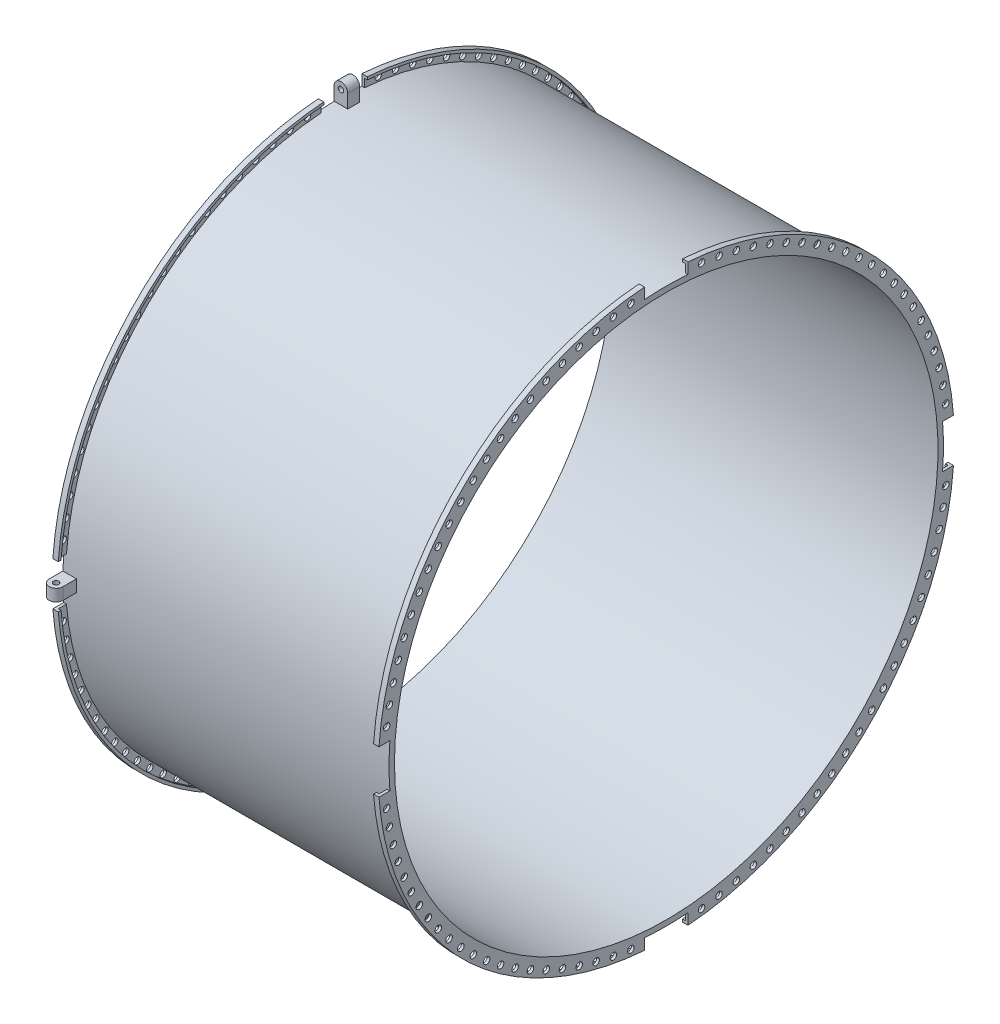
from build123d import *
from build123d.topology import SkipClean

# Parameters (mm, degrees)
KES_EKSTR_ZYON1_REACH       = 1306.531
IZIM4_R                     = 6
KES_EKSTR_ZYON2_DEPTH       = 600
IZIM5_R                     = 5
Y_KSEKLIK_EKSTR_ZYON1_DEPTH = 11
DAIRESEL_O_ALTMA11_COUNT    = 4


with BuildPart() as part:
    # Çizim1 → Döndür1 (revolve)
    with BuildSketch(Plane.XY, mode=Mode.PRIVATE) as d_nd_r1_sk:
        Polygon((0, 0), (0, 30), (10, 30), (10, 25), (5, 25), (5, 10), (595, 10), (595, 25), (590, 25), (590, 30), (600, 30), (600, 0), align=None)
    revolve(d_nd_r1_sk.sketch.rotate(Axis((0, -500, 0), (1, 0, 0)), 90), axis=Axis((0, -500, 0), (1, 0, 0)))

    # Kes-Ekstrüzyon1: up to this face of the body (flat: up to its plane)
    kes_ekstr_zyon1_end = Plane(part.part.faces().sort_by_distance((600, -500, -515.009336239))[0])
    # Çizim3 → Kes-Ekstrüzyon1 (cut, up to the picked face)
    with BuildSketch(Plane.ZY, mode=Mode.PRIVATE) as kes_ekstr_zyon1_sk1:
        with BuildLine():
            Line((-40, 28.488410469), (-40, 8.428952755))
            ThreePointArc((-40, 8.428952755), (0, 10), (40, 8.428952755))
            Line((40, 8.428952755), (40, 28.488410469))
            ThreePointArc((40, 28.488410469), (0, 30), (-40, 28.488410469))
        make_face()
    kes_ekstr_zyon1_tool1 = split(extrude(kes_ekstr_zyon1_sk1.sketch, amount=-KES_EKSTR_ZYON1_REACH, mode=Mode.PRIVATE), bisect_by=kes_ekstr_zyon1_end, keep=Keep.BOTH, mode=Mode.PRIVATE)
    # Çizim3 → Kes-Ekstrüzyon1 (cut, up to the picked face)
    with BuildSketch(Plane.ZY, mode=Mode.PRIVATE) as kes_ekstr_zyon1_sk2:
        with BuildLine():
            ThreePointArc((-508.428952755, -540), (-510, -500), (-508.428952755, -460))
            Line((-508.428952755, -460), (-528.488410469, -460))
            ThreePointArc((-528.488410469, -460), (-530, -500), (-528.488410469, -540))
            Line((-528.488410469, -540), (-508.428952755, -540))
        make_face()
    kes_ekstr_zyon1_tool2 = split(extrude(kes_ekstr_zyon1_sk2.sketch, amount=-KES_EKSTR_ZYON1_REACH, mode=Mode.PRIVATE), bisect_by=kes_ekstr_zyon1_end, keep=Keep.BOTH, mode=Mode.PRIVATE)
    # Çizim3 → Kes-Ekstrüzyon1 (cut, up to the picked face)
    with BuildSketch(Plane.ZY, mode=Mode.PRIVATE) as kes_ekstr_zyon1_sk3:
        with BuildLine():
            ThreePointArc((40, -1008.428952755), (0, -1010), (-40, -1008.428952755))
            Line((-40, -1008.428952755), (-40, -1028.488410469))
            ThreePointArc((-40, -1028.488410469), (0, -1030), (40, -1028.488410469))
            Line((40, -1028.488410469), (40, -1008.428952755))
        make_face()
    kes_ekstr_zyon1_tool3 = split(extrude(kes_ekstr_zyon1_sk3.sketch, amount=-KES_EKSTR_ZYON1_REACH, mode=Mode.PRIVATE), bisect_by=kes_ekstr_zyon1_end, keep=Keep.BOTH, mode=Mode.PRIVATE)
    # Çizim3 → Kes-Ekstrüzyon1 (cut, up to the picked face)
    with BuildSketch(Plane.ZY, mode=Mode.PRIVATE) as kes_ekstr_zyon1_sk4:
        with BuildLine():
            Line((528.488410469, -460), (508.428952755, -460))
            ThreePointArc((508.428952755, -460), (509.607086835, -479.984579761), (510, -500))
            ThreePointArc((510, -500), (509.607086835, -520.015420239), (508.428952755, -540))
            Line((508.428952755, -540), (528.488410469, -540))
            ThreePointArc((528.488410469, -540), (529.621967798, -520.014275548), (530, -500))
            ThreePointArc((530, -500), (529.621967798, -479.985724452), (528.488410469, -460))
        make_face()
    kes_ekstr_zyon1_tool4 = split(extrude(kes_ekstr_zyon1_sk4.sketch, amount=-KES_EKSTR_ZYON1_REACH, mode=Mode.PRIVATE), bisect_by=kes_ekstr_zyon1_end, keep=Keep.BOTH, mode=Mode.PRIVATE)
    add(kes_ekstr_zyon1_tool1.solids().sort_by(Axis((0, 19.486126, 0), (1, 0, 0)))[0], mode=Mode.SUBTRACT)
    add(kes_ekstr_zyon1_tool2.solids().sort_by(Axis((0, -500, -519.486126), (1, 0, 0)))[0], mode=Mode.SUBTRACT)
    add(kes_ekstr_zyon1_tool3.solids().sort_by(Axis((0, -1019.486126, 0), (1, 0, 0)))[0], mode=Mode.SUBTRACT)
    add(kes_ekstr_zyon1_tool4.solids().sort_by(Axis((0, -500, 519.486126), (1, 0, 0)))[0], mode=Mode.SUBTRACT)

    # Çizim4 → Kes-Ekstrüzyon2 (cut)
    with SkipClean():  # the faces are left unmerged after this step: merging them gives an invalid solid
        with BuildSketch(Plane.ZY):
            with Locations((0, 18.458681612)):
                Circle(IZIM4_R)
            with Locations((32.554289973, 17.435621835)):
                Circle(IZIM4_R)
            with Locations((64.980103036, 14.370480052)):
                Circle(IZIM4_R)
            with Locations((97.149469319, 9.275352977)):
                Circle(IZIM4_R)
            with Locations((128.93543103, 2.170348751)):
                Circle(IZIM4_R)
            with Locations((160.212543499, -6.916492423)):
                Circle(IZIM4_R)
            with Locations((190.857370254, -17.949308932)):
                Circle(IZIM4_R)
            with Locations((220.748970163, -30.884559291)):
                Circle(IZIM4_R)
            with Locations((249.769374737, -45.671193976)):
                Circle(IZIM4_R)
            with Locations((277.804053697, -62.250856896)):
                Circle(IZIM4_R)
            with Locations((304.742366975, -80.558115694)):
                Circle(IZIM4_R)
            with Locations((330.478001353, -100.520719986)):
                Circle(IZIM4_R)
            with Locations((354.909390041, -122.05988649)):
                Circle(IZIM4_R)
            with Locations((377.94011351, -145.090609959)):
                Circle(IZIM4_R)
            with Locations((399.479280014, -169.521998647)):
                Circle(IZIM4_R)
            with Locations((419.441884306, -195.257633025)):
                Circle(IZIM4_R)
            with Locations((437.749143104, -222.195946303)):
                Circle(IZIM4_R)
            with Locations((454.328806024, -250.230625263)):
                Circle(IZIM4_R)
            with Locations((469.115440709, -279.251029837)):
                Circle(IZIM4_R)
            with Locations((482.050691068, -309.142629746)):
                Circle(IZIM4_R)
            with Locations((493.083507577, -339.787456501)):
                Circle(IZIM4_R)
            with Locations((502.170348751, -371.06456897)):
                Circle(IZIM4_R)
            with Locations((509.275352977, -402.850530681)):
                Circle(IZIM4_R)
            with Locations((514.370480052, -435.019896964)):
                Circle(IZIM4_R)
            with Locations((517.435621835, -467.445710027)):
                Circle(IZIM4_R)
            with Locations((518.458681612, -500)):
                Circle(IZIM4_R)
            with Locations((517.435621835, -532.554289973)):
                Circle(IZIM4_R)
            with Locations((514.370480052, -564.980103036)):
                Circle(IZIM4_R)
            with Locations((509.275352977, -597.149469319)):
                Circle(IZIM4_R)
            with Locations((502.170348751, -628.93543103)):
                Circle(IZIM4_R)
            with Locations((493.083507577, -660.212543499)):
                Circle(IZIM4_R)
            with Locations((482.050691068, -690.857370254)):
                Circle(IZIM4_R)
            with Locations((469.115440709, -720.748970163)):
                Circle(IZIM4_R)
            with Locations((454.328806024, -749.769374737)):
                Circle(IZIM4_R)
            with Locations((437.749143104, -777.804053697)):
                Circle(IZIM4_R)
            with Locations((419.441884306, -804.742366975)):
                Circle(IZIM4_R)
            with Locations((399.479280014, -830.478001353)):
                Circle(IZIM4_R)
            with Locations((377.94011351, -854.909390041)):
                Circle(IZIM4_R)
            with Locations((354.909390041, -877.94011351)):
                Circle(IZIM4_R)
            with Locations((330.478001353, -899.479280014)):
                Circle(IZIM4_R)
            with Locations((304.742366975, -919.441884305)):
                Circle(IZIM4_R)
            with Locations((277.804053697, -937.749143104)):
                Circle(IZIM4_R)
            with Locations((249.769374737, -954.328806024)):
                Circle(IZIM4_R)
            with Locations((220.748970163, -969.115440709)):
                Circle(IZIM4_R)
            with Locations((190.857370254, -982.050691068)):
                Circle(IZIM4_R)
            with Locations((160.212543499, -993.083507577)):
                Circle(IZIM4_R)
            with Locations((128.93543103, -1002.170348751)):
                Circle(IZIM4_R)
            with Locations((97.149469319, -1009.275352977)):
                Circle(IZIM4_R)
            with Locations((64.980103036, -1014.370480052)):
                Circle(IZIM4_R)
            with Locations((32.554289973, -1017.435621835)):
                Circle(IZIM4_R)
            with Locations((0, -1018.458681612)):
                Circle(IZIM4_R)
            with Locations((-32.554289973, -1017.435621835)):
                Circle(IZIM4_R)
            with Locations((-64.980103036, -1014.370480052)):
                Circle(IZIM4_R)
            with Locations((-97.149469319, -1009.275352977)):
                Circle(IZIM4_R)
            with Locations((-128.93543103, -1002.170348751)):
                Circle(IZIM4_R)
            with Locations((-160.212543499, -993.083507577)):
                Circle(IZIM4_R)
            with Locations((-190.857370254, -982.050691068)):
                Circle(IZIM4_R)
            with Locations((-220.748970163, -969.115440709)):
                Circle(IZIM4_R)
            with Locations((-249.769374737, -954.328806024)):
                Circle(IZIM4_R)
            with Locations((-277.804053697, -937.749143104)):
                Circle(IZIM4_R)
            with Locations((-304.742366975, -919.441884306)):
                Circle(IZIM4_R)
            with Locations((-330.478001353, -899.479280014)):
                Circle(IZIM4_R)
            with Locations((-354.909390041, -877.94011351)):
                Circle(IZIM4_R)
            with Locations((-377.94011351, -854.909390041)):
                Circle(IZIM4_R)
            with Locations((-399.479280014, -830.478001353)):
                Circle(IZIM4_R)
            with Locations((-419.441884305, -804.742366975)):
                Circle(IZIM4_R)
            with Locations((-437.749143104, -777.804053697)):
                Circle(IZIM4_R)
            with Locations((-454.328806023, -749.769374737)):
                Circle(IZIM4_R)
            with Locations((-469.115440709, -720.748970163)):
                Circle(IZIM4_R)
            with Locations((-482.050691068, -690.857370254)):
                Circle(IZIM4_R)
            with Locations((-493.083507577, -660.212543499)):
                Circle(IZIM4_R)
            with Locations((-502.170348751, -628.93543103)):
                Circle(IZIM4_R)
            with Locations((-509.275352977, -597.149469319)):
                Circle(IZIM4_R)
            with Locations((-514.370480052, -564.980103036)):
                Circle(IZIM4_R)
            with Locations((-517.435621835, -532.554289973)):
                Circle(IZIM4_R)
            with Locations((-518.458681612, -500)):
                Circle(IZIM4_R)
            with Locations((-517.435621835, -467.445710027)):
                Circle(IZIM4_R)
            with Locations((-514.370480052, -435.019896964)):
                Circle(IZIM4_R)
            with Locations((-509.275352977, -402.850530681)):
                Circle(IZIM4_R)
            with Locations((-502.170348751, -371.06456897)):
                Circle(IZIM4_R)
            with Locations((-493.083507577, -339.787456501)):
                Circle(IZIM4_R)
            with Locations((-482.050691068, -309.142629746)):
                Circle(IZIM4_R)
            with Locations((-469.115440709, -279.251029837)):
                Circle(IZIM4_R)
            with Locations((-454.328806024, -250.230625263)):
                Circle(IZIM4_R)
            with Locations((-437.749143104, -222.195946303)):
                Circle(IZIM4_R)
            with Locations((-419.441884306, -195.257633025)):
                Circle(IZIM4_R)
            with Locations((-399.479280014, -169.521998647)):
                Circle(IZIM4_R)
            with Locations((-377.94011351, -145.090609959)):
                Circle(IZIM4_R)
            with Locations((-354.909390041, -122.05988649)):
                Circle(IZIM4_R)
            with Locations((-330.478001353, -100.520719986)):
                Circle(IZIM4_R)
            with Locations((-304.742366975, -80.558115695)):
                Circle(IZIM4_R)
            with Locations((-277.804053697, -62.250856896)):
                Circle(IZIM4_R)
            with Locations((-249.769374737, -45.671193976)):
                Circle(IZIM4_R)
            with Locations((-220.748970163, -30.884559291)):
                Circle(IZIM4_R)
            with Locations((-190.857370254, -17.949308932)):
                Circle(IZIM4_R)
            with Locations((-160.212543499, -6.916492423)):
                Circle(IZIM4_R)
            with Locations((-128.93543103, 2.170348751)):
                Circle(IZIM4_R)
            with Locations((-97.149469319, 9.275352977)):
                Circle(IZIM4_R)
            with Locations((-64.980103036, 14.370480052)):
                Circle(IZIM4_R)
            with Locations((-32.554289973, 17.435621835)):
                Circle(IZIM4_R)
        extrude(amount=-KES_EKSTR_ZYON2_DEPTH, mode=Mode.SUBTRACT)


with BuildPart() as body_2:
    # Çizim5 → Yükseklik-Ekstrüzyon1 (new, symmetric)
    with BuildSketch(Plane.XY):
        with BuildLine():
            Line((25, 10), (0, 10))
            Line((0, 10), (0, 35))
            ThreePointArc((0, 35), (12.5, 47.5), (25, 35))
            Line((25, 35), (25, 10))
        make_face()
        with Locations((12.5, 35)):
            Circle(IZIM5_R, mode=Mode.SUBTRACT)
    extrude(amount=Y_KSEKLIK_EKSTR_ZYON1_DEPTH, both=True)


with BuildPart() as dairesel_o_altma11_1:
    # Dairesel Çoğaltma11: pattern copy
    add(body_2.part.rotate(Axis((0, -500, 0), (1, 0, 0)), 1 * 360 / DAIRESEL_O_ALTMA11_COUNT))


with BuildPart() as dairesel_o_altma11_2:
    # Dairesel Çoğaltma11: pattern copy
    add(body_2.part.rotate(Axis((0, -500, 0), (1, 0, 0)), 2 * 360 / DAIRESEL_O_ALTMA11_COUNT))


with BuildPart() as dairesel_o_altma11_3:
    # Dairesel Çoğaltma11: pattern copy
    add(body_2.part.rotate(Axis((0, -500, 0), (1, 0, 0)), 3 * 360 / DAIRESEL_O_ALTMA11_COUNT))


solid = Compound([part.part, body_2.part, dairesel_o_altma11_1.part, dairesel_o_altma11_2.part, dairesel_o_altma11_3.part])
